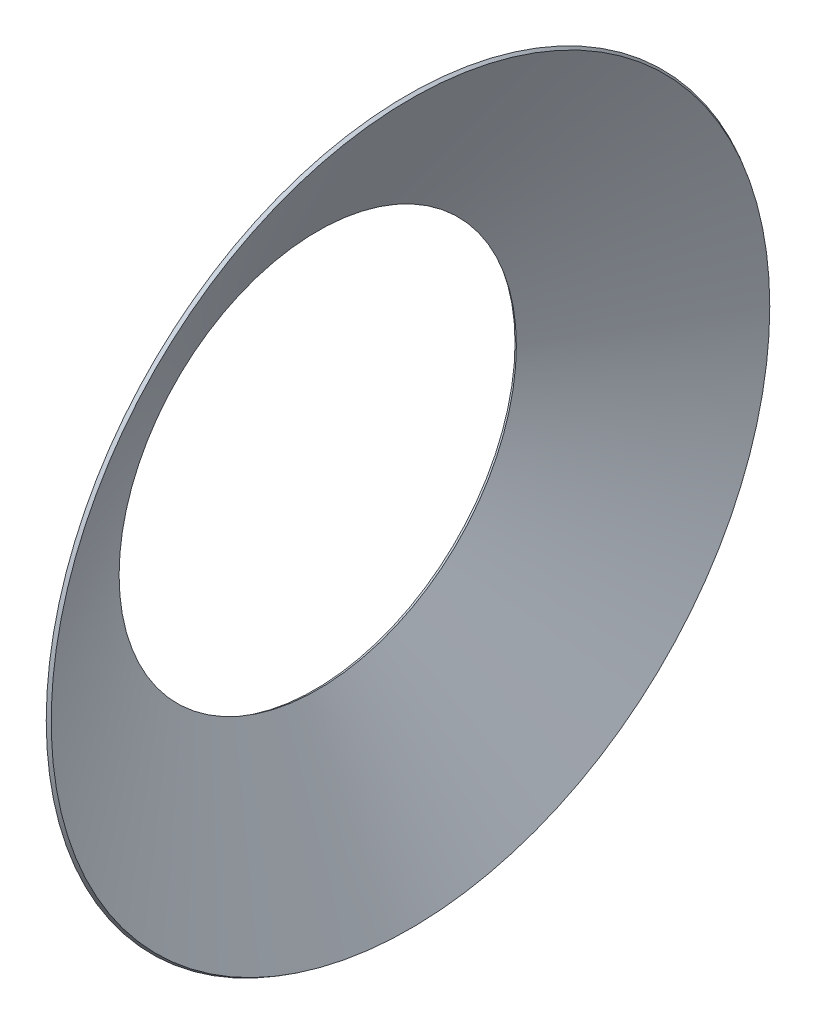
from build123d import *


with BuildPart() as part:
    # Esboço1 → Revolução1 (revolve)
    with BuildSketch(Plane.XY):
        Polygon((-2751.650021719, 4961.197800832), (-2708.348253697, 4936.198663124), (-3982.616392143, 2729), (-4025.918160165, 2753.999137708), align=None)
    revolve(axis=Axis((0, 0, 0), (-1, 0, 0)))


solid = part.part
